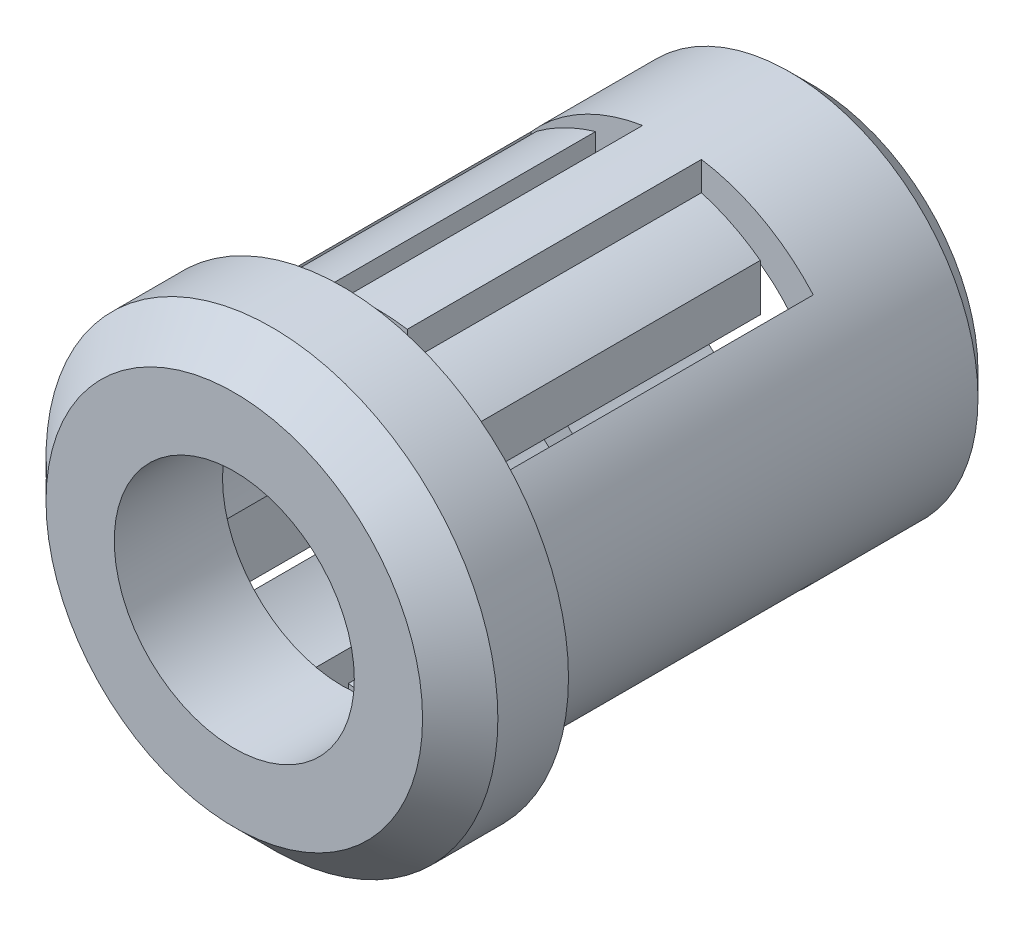
from build123d import *

# Parameters (mm, degrees)
SKETCH1_R           = 4
BOSS_EXTRUDE1_DEPTH = 10
SKETCH2_R           = 4.8
BOSS_EXTRUDE2_DEPTH = 2.3
CHAMFER1_SIZE       = 0.8
CHAMFER2_SIZE       = 0.5
SKETCH3_R           = 2.55
CUT_EXTRUDE1_DEPTH  = 3
SKETCH4_R           = 3.25
CUT_EXTRUDE2_DEPTH  = 10
CUT_EXTRUDE3_DEPTH  = 5


with BuildPart() as part:
    # Sketch1 → Boss-Extrude1 (new body)
    with BuildSketch(Plane.XY):
        Circle(SKETCH1_R)
    extrude(amount=BOSS_EXTRUDE1_DEPTH)

    # Sketch2 → Boss-Extrude2 (add)
    with BuildSketch(Plane.XY.offset(10)):
        Circle(SKETCH2_R)
    extrude(amount=BOSS_EXTRUDE2_DEPTH)

    # Chamfer1
    chamfer1_edges = [part.edges().sort_by_distance(p)[0] for p in [
        (-4.8, 0, 12.3),
    ]]
    chamfer(chamfer1_edges, length=CHAMFER1_SIZE)

    # Chamfer2
    chamfer2_edges = [part.edges().sort_by_distance(p)[0] for p in [
        (-4, 0, 0),
    ]]
    chamfer(chamfer2_edges, length=CHAMFER2_SIZE)

    # Sketch3 → Cut-Extrude1 (cut)
    with BuildSketch(Plane.XY.offset(12.3)):
        Circle(SKETCH3_R)
    extrude(amount=-CUT_EXTRUDE1_DEPTH, mode=Mode.SUBTRACT)

    # Sketch4 → Cut-Extrude2 (cut)
    with BuildSketch(Plane(origin=(0, 0, 0), x_dir=(-1, 0, 0), z_dir=(0, 0, -1))):
        Circle(SKETCH4_R)
    extrude(amount=-CUT_EXTRUDE2_DEPTH, mode=Mode.SUBTRACT)

    # Sketch5 → Cut-Extrude3 (cut, symmetric)
    with BuildSketch(Plane(origin=(0, 0, 0), x_dir=(1, 0, 0), z_dir=(0, 1, 0))):
        Polygon((-3, -10), (-2.375, -10), (-2.375, -3.5), (-1.125, -3.5), (-1.125, -10), (1.125, -10), (1.125, -3.5), (2.375, -3.5), (2.375, -10), (3, -10), (3, -3), (0.625, -3), (0.625, -9.25), (-0.625, -9.25), (-0.625, -3), (-3, -3), align=None)
    extrude(amount=CUT_EXTRUDE3_DEPTH, both=True, mode=Mode.SUBTRACT)


solid = part.part
